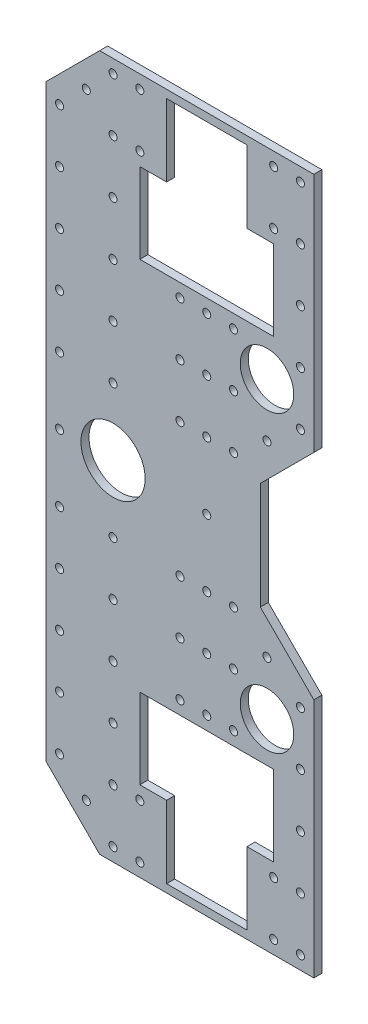
from build123d import *
from build123d.topology import SkipClean

# Parameters (mm, degrees)
MAIN_DEPTH                      = 3
SKETCH2_R                       = 12
SKETCH2_R_2                     = 1.5
SKETCH2_R_3                     = 10
SINGLEHOLES_DEPTH               = 144.209636547
SKETCH3_R                       = 1.5
TOPLEFTHOLE_DEPTH               = 144.209636547
TOPLEFT2HOLELINEARPATTERN_COUNT = 6
TOPLEFT2HOLELINEARPATTERN_PITCH = 20
SKETCH4_R                       = 1.5
TOPLEFT1HOLE_DEPTH              = 144.209636547
TOPLEFT1HOLELINEARPATTERN_COUNT = 5
TOPLEFT1HOLELINEARPATTERN_PITCH = 20
SKETCH5_R                       = 1.5
TOPRIGHTHOLE_DEPTH              = 144.209636547
TOPRIGHTHOLELINEARPATTERN_COUNT = 5
TOPRIGHTHOLELINEARPATTERN_PITCH = 20
MOTORHOLEFIXSKETCH_R            = 1.5
MOTORHOLEFIX_DEPTH              = 144.209636547
MOTORHOLEFIXLINEARPATTERN_COUNT = 3
MOTORHOLEFIXLINEARPATTERN_PITCH = 20
SKETCH6_R                       = 1.5
CUT_EXTRUDE1_DEPTH              = 144.209636547


with BuildPart() as part:
    # Sketch1 → Main (new body)
    with BuildSketch(Plane.XY):
        Polygon((-60, 110), (-60, 0), (20, 0), (20, 20), (40, 40), (40, 130), (-40, 130), align=None)
        Polygon((-25, 100), (-15, 100), (-15, 127), (15, 127), (15, 100), (25, 100), (25, 70), (-25, 70), align=None, mode=Mode.SUBTRACT)
    extrude(amount=MAIN_DEPTH)

    # Sketch2 → SingleHoles (cut, through all)
    with BuildSketch(Plane.XY.offset(3)):
        with Locations((-35, 0)):
            Circle(SKETCH2_R)
        with Locations((-55, 0)):
            Circle(SKETCH2_R_2)
        with Locations((22.5, 55)):
            Circle(SKETCH2_R_3)
        Circle(SKETCH2_R_2)
        with Locations((-45, 115)):
            Circle(SKETCH2_R_2)
        with Locations((22.5, 35)):
            Circle(SKETCH2_R_2)
    extrude(amount=-SINGLEHOLES_DEPTH, mode=Mode.SUBTRACT)

    # Sketch3 → TopLeftHole (cut, through all)
    with BuildSketch(Plane.XY.offset(3)):
        with Locations((-35, 125)):
            Circle(SKETCH3_R)
    toplefthole = extrude(amount=-TOPLEFTHOLE_DEPTH, mode=Mode.SUBTRACT)

    # TopLeft2HoleLinearPattern: TopLeftHole ×6
    with Locations(*[(0, -i * TOPLEFT2HOLELINEARPATTERN_PITCH, 0) for i in range(1, TOPLEFT2HOLELINEARPATTERN_COUNT)]):
        add(toplefthole, mode=Mode.SUBTRACT)

    # Sketch4 → TopLeft1Hole (cut, through all)
    with BuildSketch(Plane.XY.offset(3)):
        with Locations((-35, 105)):
            Circle(SKETCH4_R)
        with Locations((-55, 105)):
            Circle(SKETCH4_R)
    topleft1hole = extrude(amount=-TOPLEFT1HOLE_DEPTH, mode=Mode.SUBTRACT)

    # TopLeft1HoleLinearPattern: TopLeft1Hole ×5
    with Locations(*[(0, -i * TOPLEFT1HOLELINEARPATTERN_PITCH, 0) for i in range(1, TOPLEFT1HOLELINEARPATTERN_COUNT)]):
        add(topleft1hole, mode=Mode.SUBTRACT)

    # Sketch5 → TopRightHole (cut, through all)
    with BuildSketch(Plane.XY.offset(3)):
        with Locations((35, 125)):
            Circle(SKETCH5_R)
    toprighthole = extrude(amount=-TOPRIGHTHOLE_DEPTH, mode=Mode.SUBTRACT)

    # TopRightHoleLinearPattern: TopRightHole ×5
    with Locations(*[(0, -i * TOPRIGHTHOLELINEARPATTERN_PITCH, 0) for i in range(1, TOPRIGHTHOLELINEARPATTERN_COUNT)]):
        add(toprighthole, mode=Mode.SUBTRACT)

    # MotorHoleFixSketch → MotorHoleFix (cut, through all)
    with BuildSketch(Plane.XY.offset(3)):
        with Locations((0, 65)):
            Circle(MOTORHOLEFIXSKETCH_R)
        with Locations((-10, 65)):
            Circle(MOTORHOLEFIXSKETCH_R)
        with Locations((10, 65)):
            Circle(MOTORHOLEFIXSKETCH_R)
    motorholefix = extrude(amount=-MOTORHOLEFIX_DEPTH, mode=Mode.SUBTRACT)

    # MotorHoleFixLinearPattern: MotorHoleFix ×3
    with Locations(*[(0, -i * MOTORHOLEFIXLINEARPATTERN_PITCH, 0) for i in range(1, MOTORHOLEFIXLINEARPATTERN_COUNT)]):
        add(motorholefix, mode=Mode.SUBTRACT)

    # Sketch6 → Cut-Extrude1 (cut, through all)
    with BuildSketch(Plane.XY.offset(3)):
        with Locations((25, 125)):
            Circle(SKETCH6_R)
        with Locations((25, 105)):
            Circle(SKETCH6_R)
    cut_extrude1 = extrude(amount=-CUT_EXTRUDE1_DEPTH, mode=Mode.SUBTRACT)

    # Mirror1: Cut-Extrude1 across plane
    add(cut_extrude1.mirror(Plane(origin=(0, 0, 0), x_dir=(0, 0, 1), z_dir=(1, 0, 0))), mode=Mode.SUBTRACT)

    # LeftRightMirror: part across plane


with BuildPart() as part_1:
    with SkipClean():  # the faces are left unmerged after this step: merging them gives an invalid solid
        add(part.part)
        add(part.part.mirror(Plane.ZX))


solid = part_1.part
